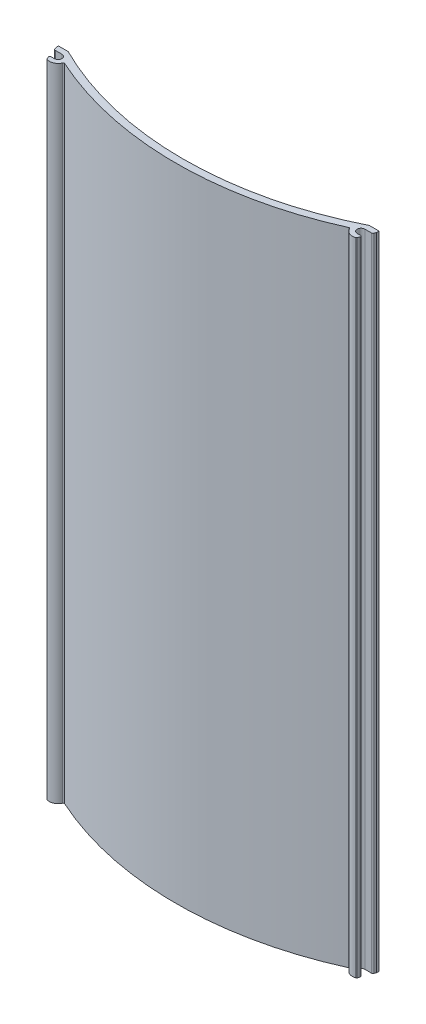
from build123d import *
from build123d.topology import SkipClean

# Parameters (mm, degrees)
BOSS_EXTRUDE1_DEPTH = 203.2
CUT_EXTRUDE1_DEPTH  = 204.2
BOSS_EXTRUDE2_DEPTH = 203.2
FILLET1_R           = 0.508
BOSS_EXTRUDE3_DEPTH = 203.2
CUT_EXTRUDE2_DEPTH  = 204.2
FILLET2_R           = 0.381


with BuildPart() as part:
    # Sketch1 → Boss-Extrude1 (new body)
    with BuildSketch(Plane(origin=(0, 0, 0), x_dir=(1, 0, 0), z_dir=(0, 1, 0))):
        with BuildLine():
            Line((101.58476, 5.338063609), (101.58476, 6.354063609))
            ThreePointArc((101.58476, 6.354063609), (50.79238, 19.05), (0, 6.354063609))
            Line((0, 6.354063609), (0, 5.338063609))
            Line((0, 5.338063609), (1.338554634, 5.338063609))
            ThreePointArc((1.338554634, 5.338063609), (45.188812602, 17.378377427), (90.062082389, 10.016044959))
            ThreePointArc((90.062082389, 10.016044959), (91.218156641, 9.549225792), (92.368682931, 9.068895628))
            ThreePointArc((92.368682931, 9.068895628), (96.251044015, 7.328911154), (100.06076, 5.435148318))
            Line((100.06076, 5.435148318), (100.06076, 4.322063609))
            ThreePointArc((100.06076, 4.322063609), (100.209549755, 3.962853364), (100.56876, 3.814063609))
            Line((100.56876, 3.814063609), (100.82276, 3.814063609))
            Line((100.82276, 3.814063609), (101.58476, 5.338063609))
        make_face()
    extrude(amount=BOSS_EXTRUDE1_DEPTH)

    # Sketch3 → Cut-Extrude1 (cut, through all)
    with BuildSketch(Plane(origin=(0, 203.2, 0), x_dir=(1, 0, 0), z_dir=(0, 1, 0))):
        Polygon((100.06076, 2.923708758), (101.58476, 2.923708758), (101.58476, 5.592063609), (100.06076, 5.435148318), align=None)
        Polygon((0, 5.592063609), (0.4067845, 4.474432381), (0, 4.474432381), align=None)
    extrude(amount=-CUT_EXTRUDE1_DEPTH, mode=Mode.SUBTRACT)

    # Sketch2 → Boss-Extrude2 (add)
    with BuildSketch(Plane(origin=(0, 203.2, 0), x_dir=(1, 0, 0), z_dir=(0, 1, 0))):
        with BuildLine():
            Line((98.79076, 4.639563606), (101.238078351, 4.639563606))
            Line((101.238078351, 4.639563606), (101.58476, 5.592063609))
            Line((101.58476, 5.592063609), (100.06076, 5.435148318))
            ThreePointArc((100.06076, 5.435148318), (99.355551952, 5.800115132), (98.647640508, 6.159810213))
            ThreePointArc((98.647640508, 6.159810213), (96.114471858, 2.891665388), (99.718733273, 0.865088556))
            ThreePointArc((99.718733273, 0.865088556), (99.858345852, 0.953692868), (99.947271519, 1.093100982))
            Line((99.947271519, 1.093100982), (100.173716674, 1.715253931))
            ThreePointArc((100.173716674, 1.715253931), (100.127790714, 2.064096228), (99.815693785, 2.226563606))
            Line((99.815693785, 2.226563606), (98.79076, 2.226563606))
            ThreePointArc((98.79076, 2.226563606), (97.58426, 3.433063606), (98.79076, 4.639563606))
        make_face()
        with BuildLine():
            ThreePointArc((1.769066215, 2.226563606), (1.456969286, 2.064096228), (1.411043326, 1.715253931))
            Line((1.411043326, 1.715253931), (1.637488481, 1.093100982))
            ThreePointArc((1.637488481, 1.093100982), (1.726414148, 0.953692868), (1.866026727, 0.865088556))
            ThreePointArc((1.866026727, 0.865088556), (5.470288142, 2.891665388), (2.937119492, 6.159810213))
            ThreePointArc((2.937119492, 6.159810213), (2.136102242, 5.752311703), (1.338554634, 5.338063609))
            Line((1.338554634, 5.338063609), (0.09244844, 5.338063609))
            Line((0.09244844, 5.338063609), (0.346681649, 4.639563606))
            Line((0.346681649, 4.639563606), (2.794, 4.639563606))
            ThreePointArc((2.794, 4.639563606), (4.0005, 3.433063606), (2.794, 2.226563606))
            Line((2.794, 2.226563606), (1.769066215, 2.226563606))
        make_face()
    extrude(amount=-BOSS_EXTRUDE2_DEPTH)

    # Fillet1
    fillet1_edges = [part.edges().sort_by_distance(p)[0] for p in [
        (101.238078351, 101.6, -4.639563606),
        (0.346681649, 101.6, -4.639563606),
    ]]
    fillet(fillet1_edges, radius=FILLET1_R)

    # Sketch4 → Boss-Extrude3 (add, through all)
    with BuildSketch(Plane(origin=(0, 203.2, 0), x_dir=(1, 0, 0), z_dir=(0, 1, 0))):
        with BuildLine():
            ThreePointArc((3.991870192, 5.886782672), (5.288114571, 4.544379384), (5.419434578, 2.682914602))
            ThreePointArc((5.419434578, 2.682914602), (50.79238, -7.212984057), (96.165325422, 2.682914602))
            ThreePointArc((96.165325422, 2.682914602), (96.296645429, 4.544379384), (97.592889808, 5.886782672))
            ThreePointArc((97.592889808, 5.886782672), (50.79238, -4.926984057), (3.991870192, 5.886782672))
        make_face()
        with BuildLine():
            ThreePointArc((2.937119492, 6.159810213), (3.478250935, 6.076438514), (3.991870192, 5.886782672))
            ThreePointArc((3.991870192, 5.886782672), (3.588373028, 6.084817853), (3.185713825, 6.284551329))
            ThreePointArc((3.185713825, 6.284551329), (3.061375909, 6.222261981), (2.937119492, 6.159810213))
        make_face()
        with BuildLine():
            ThreePointArc((98.399046175, 6.284551329), (97.996386972, 6.084817853), (97.592889808, 5.886782672))
            ThreePointArc((97.592889808, 5.886782672), (98.106509065, 6.076438514), (98.647640508, 6.159810213))
            ThreePointArc((98.647640508, 6.159810213), (98.523384091, 6.222261981), (98.399046175, 6.284551329))
        make_face()
    extrude(amount=-BOSS_EXTRUDE3_DEPTH)

    # Sketch5 → Cut-Extrude2 (cut, through all)
    with SkipClean():  # keep this step's faces unmerged: merging them makes the solid invalid here
        with BuildSketch(Plane(origin=(0, 203.2, 0), x_dir=(1, 0, 0), z_dir=(0, 1, 0))):
            with BuildLine():
                ThreePointArc((98.399046175, 6.284551329), (98.468630342, 6.31928211), (98.538189172, 6.354063609))
                Line((98.538189172, 6.354063609), (101.58476, 6.354063609))
                ThreePointArc((101.58476, 6.354063609), (50.79238, 19.05), (0, 6.354063609))
                Line((0, 6.354063609), (3.046570828, 6.354063609))
                ThreePointArc((3.046570828, 6.354063609), (3.116129658, 6.31928211), (3.185713825, 6.284551329))
                ThreePointArc((3.185713825, 6.284551329), (50.79238, 17.526), (98.399046175, 6.284551329))
            make_face()
        extrude(amount=-CUT_EXTRUDE2_DEPTH, mode=Mode.SUBTRACT)

    # Fillet2
    fillet2_edges = [part.edges().sort_by_distance(p)[0] for p in [
        (5.419434578, 101.6, -2.682914602),
        (96.165325422, 101.6, -2.682914602),
    ]]
    fillet(fillet2_edges, radius=FILLET2_R)


solid = part.part
